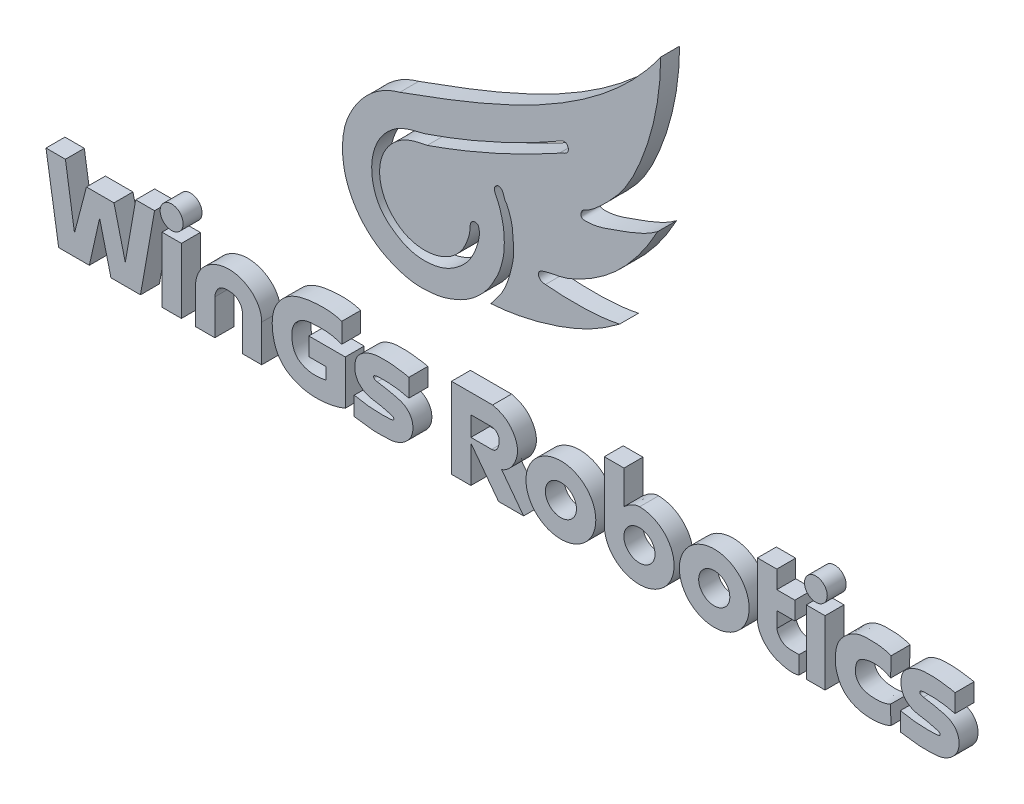
from build123d import *

# Parameters (mm, degrees)
SKETCH1_W           = 116
SKETCH1_H           = 86
BOSS_EXTRUDE1_DEPTH = 2
SKETCH2_W           = 116
SKETCH2_H           = 86
SKETCH2_W_2         = 2.050080953
SKETCH2_H_2         = 6.874434124
SKETCH2_R           = 1.213859124
SKETCH2_W_3         = 1.981029746
SKETCH2_H_3         = 6.809423223
SKETCH2_R_2         = 1.204225855
CUT_EXTRUDE2_DEPTH  = 11


with BuildPart() as part:
    # Sketch1 → Boss-Extrude1 (new body)
    with BuildSketch(Plane.XY):
        with Locations((58, 43)):
            Rectangle(SKETCH1_W, SKETCH1_H)
    extrude(amount=BOSS_EXTRUDE1_DEPTH)

    # Sketch2 → Cut-Extrude2 (cut)
    with BuildSketch(Plane.XY.offset(2)):
        with Locations((58, 43)):
            Rectangle(SKETCH2_W, SKETCH2_H)
        Polygon((11.140293702, 19.790279863), (9.80265223, 28.23498876), (11.852733183, 28.23498876), (12.812345543, 21.968429251), (14.07728911, 26.810109799), (16.985205355, 26.810109799), (18.177451016, 21.968429251), (19.282459189, 28.23498876), (21.274381817, 28.23498876), (19.785291617, 19.790279863), (16.665334568, 19.790279863), (15.467765439, 24.653578889), (14.382620316, 19.790279863), align=None, mode=Mode.SUBTRACT)
        with Locations((23.08455968, 23.227496925)):
            Rectangle(SKETCH2_W_2, SKETCH2_H_2, mode=Mode.SUBTRACT)
        with Locations((23.077289889, 28.540319965)):
            Circle(SKETCH2_R, mode=Mode.SUBTRACT)
        with BuildLine():
            add(Edge.make_bspline(
                [(25.597182949, 23.698574699), (25.655024383, 24.365774688), (26.094095564, 25.511687071), (27.542408981, 26.573688518), (30.276837479, 27.206654041), (32.573603491, 25.561936036), (32.593329118, 23.698574699)],
                knots=[0, 0, 0, 0, 0.198571456, 0.340640158, 0.513500481, 1, 1, 1, 1], degree=3))
            Line((32.593329118, 23.698574699), (32.593329118, 19.790279863))
            Line((32.593329118, 19.790279863), (30.550507488, 19.790279863))
            Line((30.550507488, 19.790279863), (30.550507488, 23.53425261))
            add(Edge.make_bspline(
                [(30.550507488, 23.53425261), (30.543410322, 23.975896739), (30.106824896, 24.716492763), (29.076011424, 24.858477486), (28.007386667, 24.772266409), (27.672864704, 23.933055449), (27.642687936, 23.53425261)],
                knots=[0, 0, 0, 0, 0.311205264, 0.495487823, 0.702071237, 1, 1, 1, 1], degree=3))
            Line((27.642687936, 23.53425261), (27.642687936, 19.790279863))
            Line((27.642687936, 19.790279863), (25.597182949, 19.790279863))
            Line((25.597182949, 19.790279863), (25.597182949, 23.698574699))
        make_face(mode=Mode.SUBTRACT)
        with BuildLine():
            Line((41.424471902, 24.925589684), (41.424471902, 20.231702472))
            add(Edge.make_bspline(
                [(41.058476828, 28.008964275), (40.053420622, 28.339513511), (38.252788176, 28.348289283), (35.579957653, 27.861823316), (33.807127389, 26.011782786), (33.590864529, 23.48949894), (34.259884703, 21.082821932), (36.595364, 19.679501372), (39.068594523, 19.5440089), (40.723497475, 19.936398387), (41.424471902, 20.231702472)],
                knots=[0, 0, 0, 0, 0.156695014, 0.267521344, 0.399378103, 0.502861963, 0.63762312, 0.747872283, 0.886034629, 1, 1, 1, 1], degree=3))
            Line((41.058476828, 28.008964275), (41.058476828, 25.902909309))
            add(Edge.make_bspline(
                [(39.392903947, 21.787154833), (38.709328807, 21.648731932), (37.576908234, 21.542273573), (36.102464246, 22.345223797), (35.704866734, 23.743461009), (35.813146547, 25.200823073), (36.969778747, 26.203973561), (38.234458734, 26.273280017), (39.623410218, 26.318179205), (40.523608068, 26.087789356), (41.058476828, 25.902909309)],
                knots=[0, 0, 0, 0, 0.18146663, 0.284134985, 0.402884015, 0.534993454, 0.639880998, 0.765013074, 0.852735118, 1, 1, 1, 1], degree=3))
            Line((39.392903947, 21.787154833), (39.392903947, 23.026010695))
            Line((39.392903947, 23.026010695), (37.575915349, 23.026010695))
            Line((37.575915349, 23.026010695), (37.575915349, 24.925589684))
            Line((37.575915349, 24.925589684), (41.424471902, 24.925589684))
        make_face(mode=Mode.SUBTRACT)
        with BuildLine():
            add(Edge.make_bspline(
                [(44.806139371, 24.345586206), (45.423564394, 24.273968664), (46.288006885, 24.064813555), (47.46290877, 23.806737598), (48.147012509, 23.319049527), (48.545595153, 22.590177306), (48.619598313, 21.763304801), (48.319682406, 20.806370209), (47.572161935, 20.139557196), (46.608821821, 19.710816999), (45.568962771, 19.681190723), (44.121341532, 19.640413074), (43.061307266, 19.870150262), (42.372568114, 19.942636104)],
                knots=[0, 0, 0, 0, 0.150365809, 0.21715787, 0.290606041, 0.346071454, 0.414260527, 0.486930119, 0.581715223, 0.647372918, 0.740088904, 0.830726665, 1, 1, 1, 1], degree=3))
            Line((42.372568114, 19.942636104), (42.372568114, 21.90410986))
            add(Edge.make_bspline(
                [(42.372568114, 21.90410986), (42.852483981, 21.803658023), (43.540520525, 21.684742464), (44.478218307, 21.597026122), (45.194509725, 21.588266366), (45.868754908, 21.582787144), (46.30052186, 21.631307616), (46.529651689, 21.687660928), (46.556676317, 21.797012759), (46.552265055, 21.96425316), (46.37902786, 22.020999474), (46.317322138, 22.049037935)],
                knots=[0, 0, 0, 0, 0.315552381, 0.449832635, 0.605449321, 0.778844328, 0.876434538, 0.897820479, 0.917220083, 0.942476197, 1, 1, 1, 1], degree=3))
            add(Edge.make_bspline(
                [(46.317322138, 22.049037935), (45.824731993, 22.210742689), (44.975778867, 22.40163227), (43.648132153, 22.55699702), (42.701652483, 23.251908996), (42.420499941, 24.163498462), (42.431107022, 24.854255388), (42.572538443, 25.490668332), (43.004076818, 26.004420138), (43.507908782, 26.358764483), (44.109433868, 26.601004045), (44.74426891, 26.734288086), (45.445562789, 26.743327695), (46.262343534, 26.742582693), (47.164011558, 26.592971419), (47.832474332, 26.519558956), (48.148216766, 26.428077311)],
                knots=[0, 0, 0, 0, 0.129354314, 0.216840147, 0.332807427, 0.395281765, 0.447955501, 0.504878839, 0.55358992, 0.611567985, 0.657300196, 0.714661081, 0.77238727, 0.832100329, 0.918345636, 1, 1, 1, 1], degree=3))
            Line((48.148216766, 26.428077311), (48.148216766, 24.517425483))
            add(Edge.make_bspline(
                [(48.148216766, 24.517425483), (46.54397318, 24.945679792), (44.888792958, 24.852708279)],
                knots=[0, 0, 0, 1, 1, 1], degree=2))
            add(Edge.make_bspline(
                [(44.888792958, 24.852708279), (44.689182117, 24.848786999), (44.51078328, 24.752820598)],
                knots=[0, 0, 0, 1, 1, 1], degree=2))
            add(Edge.make_bspline(
                [(44.51078328, 24.752820598), (44.406308103, 24.717681376), (44.387924492, 24.412408384), (44.702186936, 24.383832223), (44.806139371, 24.345586206)],
                knots=[0, 0, 0, 0, 0.400794389, 1, 1, 1, 1], degree=3))
        make_face(mode=Mode.SUBTRACT)
        with BuildLine():
            add(Edge.make_bspline(
                [(56.993288194, 28.316464094), (57.507888583, 28.199947411), (58.406020002, 27.861332004), (59.304855599, 26.802490907), (59.764827962, 25.5392533), (59.345117638, 23.970677964), (58.578129601, 23.113462352), (57.950903995, 22.876918969)],
                knots=[0, 0, 0, 0, 0.21664701, 0.372499043, 0.551296922, 0.738033031, 1, 1, 1, 1], degree=3))
            Line((57.950903995, 22.876918969), (60.268122243, 19.79950217))
            Line((60.268122243, 19.79950217), (57.623356652, 19.79950217))
            Line((57.623356652, 19.79950217), (54.699102304, 23.683102457))
            Line((54.699102304, 23.683102457), (54.699102304, 19.79950217))
            Line((54.699102304, 19.79950217), (52.650010924, 19.79950217))
            Line((52.650010924, 19.79950217), (52.650010924, 28.316464094))
            Line((52.650010924, 28.316464094), (56.993288194, 28.316464094))
        make_face(mode=Mode.SUBTRACT)
        with BuildLine():
            add(Edge.make_bspline(
                [(60.520652519, 23.223770711), (60.520652519, 17.012049197), (66.052713203, 20.117909954), (71.584773886, 23.223770711), (66.052713203, 26.329631468), (60.520652519, 29.435492225), (60.520652519, 23.223770711)],
                knots=[0, 0, 0, 2.094395102, 2.094395102, 4.188790205, 4.188790205, 6.283185307, 6.283185307, 6.283185307], degree=2, weights=[1, 0.5, 1, 0.5, 1, 0.5, 1]))
        make_face(mode=Mode.SUBTRACT)
        with BuildLine():
            Line((68.819382849, 23.63112519), (68.793403111, 29.486042678))
            Line((68.793403111, 29.486042678), (70.875700117, 29.486042678))
            Line((70.875700117, 29.486042678), (70.875700117, 25.957189376))
            add(Edge.make_bspline(
                [(70.875700117, 25.957189376), (71.166477188, 26.20926662), (71.655724283, 26.56346003), (72.234921297, 26.761658442), (72.450088475, 26.768760138)],
                knots=[0, 0, 0, 0, 0.616176335, 0.959930277, 0.959930277, 0.959930277, 0.959930277], degree=3))
            add(Edge.make_bspline(
                [(72.450088475, 26.768760138), (72.475169465, 26.769587948), (72.500355825, 26.769547878), (72.525641569, 26.768570447)],
                knots=[0.959930277, 0.959930277, 0.959930277, 0.959930277, 1, 1, 1, 1], degree=3))
            add(Edge.make_bspline(
                [(68.819382849, 23.63112519), (67.662000297, 14.258830949), (74.941664532, 20.549874967), (82.00157216, 26.651006588), (72.525641569, 26.768570447)],
                knots=[6.176447512, 6.176447512, 6.176447512, 8.596254133, 8.596254133, 10.989752867, 10.989752867, 10.989752867], degree=2, weights=[1, 0.353109864, 1, 0.360142786, 0.986087077]))
        make_face(mode=Mode.SUBTRACT)
        with BuildLine():
            add(Edge.make_bspline(
                [(76.723043602, 23.258188157), (76.723043602, 17.046466643), (82.255104285, 20.1523274), (87.787164969, 23.258188157), (82.255104285, 26.364048914), (76.723043602, 29.469909671), (76.723043602, 23.258188157)],
                knots=[0, 0, 0, 2.094395102, 2.094395102, 4.188790205, 4.188790205, 6.283185307, 6.283185307, 6.283185307], degree=2, weights=[1, 0.5, 1, 0.5, 1, 0.5, 1]))
        make_face(mode=Mode.SUBTRACT)
        with BuildLine():
            Line((84.974819681, 22.876918969), (84.974819681, 28.316464094))
            Line((84.974819681, 28.316464094), (87.019259344, 28.316464094))
            Line((87.019259344, 28.316464094), (87.019259344, 26.428077311))
            Line((87.019259344, 26.428077311), (88.927403029, 26.428077311))
            Line((88.927403029, 26.428077311), (88.927403029, 24.517425483))
            Line((88.927403029, 24.517425483), (87.019259344, 24.517425483))
            Line((87.019259344, 24.517425483), (87.019259344, 22.876918969))
            add(Edge.make_bspline(
                [(89.369700044, 21.656437237), (88.886440556, 21.681452245), (88.103178845, 21.552378339), (87.281716916, 22.165179144), (87.087153612, 22.617862686), (87.019259344, 22.876918969)],
                knots=[0, 0, 0, 0, 0.514659913, 0.724878499, 1, 1, 1, 1], degree=3))
            Line((89.369700044, 21.656437237), (89.369700044, 19.790279863))
            add(Edge.make_bspline(
                [(87.019259344, 20.009497646), (87.764844995, 19.766104306), (88.592472755, 19.517741572), (89.369700044, 19.790279863)],
                knots=[0, 0, 0, 0, 1, 1, 1, 1], degree=3))
            add(Edge.make_bspline(
                [(84.974819681, 22.876918969), (84.904874023, 21.581617108), (85.880370875, 20.470748303), (87.019259344, 20.009497646)],
                knots=[0, 0, 0, 0, 1, 1, 1, 1], degree=3))
        make_face(mode=Mode.SUBTRACT)
        with Locations((91.132775555, 23.194991475)):
            Rectangle(SKETCH2_W_3, SKETCH2_H_3, mode=Mode.SUBTRACT)
        with BuildLine():
            add(Edge.make_bspline(
                [(99.107363386, 26.428077311), (98.706813514, 26.570619476), (98.057086859, 26.739047265), (97.144064108, 26.769744551), (96.425929948, 26.789005977), (95.6235266, 26.680118298), (94.766663587, 26.291049934), (94.018726516, 25.642257941), (93.394133402, 24.752120489), (93.19884016, 23.708895909), (93.18851624, 22.662055822), (93.450358204, 21.640092766), (94.692233145, 19.432342362), (97.670513165, 19.369727476), (99.076222909, 20.009497646)],
                knots=[0, 0, 0, 0, 0.080031766, 0.124597918, 0.17129882, 0.21488749, 0.275500126, 0.344981473, 0.39882164, 0.47645066, 0.539473476, 0.594476939, 0.673244535, 1, 1, 1, 1], degree=3))
            Line((99.107363386, 26.428077311), (99.045082433, 24.345586206))
            add(Edge.make_bspline(
                [(99.045082433, 24.345586206), (98.140817478, 24.917670358), (96.933385238, 25.010368916), (95.962175283, 24.517425483)],
                knots=[0, 0, 0, 0, 1, 1, 1, 1], degree=3))
            add(Edge.make_bspline(
                [(95.962175283, 24.517425483), (95.590503523, 24.35964368), (95.371380246, 23.80674187), (95.284997638, 23.024137326), (95.465768646, 22.395754832), (95.907523378, 21.960247649), (96.471324165, 21.728931484), (97.52614725, 21.584707283), (98.434101144, 21.657237599), (99.045082433, 21.968429251)],
                knots=[0, 0, 0, 0, 0.178931515, 0.272004473, 0.383258516, 0.483726003, 0.563109197, 0.676720983, 1, 1, 1, 1], degree=3))
            Line((99.045082433, 21.968429251), (99.076222909, 20.009497646))
        make_face(mode=Mode.SUBTRACT)
        with Locations((91.149003897, 28.540319965)):
            Circle(SKETCH2_R_2, mode=Mode.SUBTRACT)
        with BuildLine():
            add(Edge.make_bspline(
                [(102.515237443, 24.338180385), (103.132662467, 24.266562843), (103.997104957, 24.057407734), (105.172006842, 23.799331777), (105.856110582, 23.311643706), (106.254693225, 22.582771485), (106.328696385, 21.75589898), (106.028780479, 20.798964389), (105.281260008, 20.132151375), (104.317919893, 19.703411179), (103.278060843, 19.673784902), (101.830439604, 19.633007253), (100.770405338, 19.862744441), (100.081666186, 19.935230284)],
                knots=[0, 0, 0, 0, 0.150365809, 0.21715787, 0.290606041, 0.346071454, 0.414260527, 0.486930119, 0.581715223, 0.647372918, 0.740088904, 0.830726665, 1, 1, 1, 1], degree=3))
            Line((100.081666186, 19.935230284), (100.081666186, 21.89670404))
            add(Edge.make_bspline(
                [(100.081666186, 21.89670404), (100.561582053, 21.796252202), (101.249618597, 21.677336643), (102.18731638, 21.589620301), (102.903607798, 21.580860546), (103.57785298, 21.575381323), (104.009619933, 21.623901795), (104.238749761, 21.680255107), (104.265774389, 21.789606938), (104.261363127, 21.95684734), (104.088125932, 22.013593653), (104.02642021, 22.041632114)],
                knots=[0, 0, 0, 0, 0.315552381, 0.449832635, 0.605449321, 0.778844328, 0.876434538, 0.897820479, 0.917220083, 0.942476197, 1, 1, 1, 1], degree=3))
            add(Edge.make_bspline(
                [(104.02642021, 22.041632114), (103.533830066, 22.203336869), (102.68487694, 22.394226449), (101.357230225, 22.5495912), (100.410750556, 23.244503176), (100.129598013, 24.156092641), (100.140205094, 24.846849567), (100.281636516, 25.483262512), (100.71317489, 25.997014317), (101.217006854, 26.351358662), (101.81853194, 26.593598224), (102.453366982, 26.726882265), (103.154660861, 26.735921874), (103.971441607, 26.735176872), (104.87310963, 26.585565598), (105.541572404, 26.512153135), (105.857314838, 26.420671491)],
                knots=[0, 0, 0, 0, 0.129354314, 0.216840147, 0.332807427, 0.395281765, 0.447955501, 0.504878839, 0.55358992, 0.611567985, 0.657300196, 0.714661081, 0.77238727, 0.832100329, 0.918345636, 1, 1, 1, 1], degree=3))
            Line((105.857314838, 26.420671491), (105.857314838, 24.510019662))
            add(Edge.make_bspline(
                [(105.857314838, 24.510019662), (104.253071252, 24.938273972), (102.59789103, 24.845302458)],
                knots=[0, 0, 0, 1, 1, 1], degree=2))
            add(Edge.make_bspline(
                [(102.59789103, 24.845302458), (102.398280189, 24.841381178), (102.219881352, 24.745414777)],
                knots=[0, 0, 0, 1, 1, 1], degree=2))
            add(Edge.make_bspline(
                [(102.219881352, 24.745414777), (102.115406175, 24.710275556), (102.097022564, 24.405002563), (102.411285008, 24.376426403), (102.515237443, 24.338180385)],
                knots=[0, 0, 0, 0, 0.400794389, 1, 1, 1, 1], degree=3))
        make_face(mode=Mode.SUBTRACT)
        with BuildLine():
            add(Edge.make_bspline(
                [(58.454232807, 47.516375152), (58.155201107, 47.766256761), (58.242612626, 48.405648514), (57.63435824, 48.725818852), (57.33951575, 48.561080563), (57.148056352, 48.331669293), (57.191833565, 47.968880637), (57.373109598, 47.594828313), (57.64633552, 47.047787141), (57.835821816, 46.438243828), (58.054855682, 45.66789616), (58.183227128, 44.904585404), (58.245836004, 43.851782874), (58.214820236, 42.740629424), (57.93171993, 41.583185887), (57.630830141, 40.625252894), (57.159571505, 39.759385244), (56.516222929, 38.60157538), (55.42470024, 37.436336943), (54.116750982, 36.463653396), (52.894350187, 35.923293203), (51.77243295, 35.514319825), (50.450751358, 35.31741506), (48.783731824, 35.237164884), (46.898690964, 35.69687239), (44.924093636, 36.617380122), (43.161708961, 38.106675964), (42.003804738, 39.901498444), (41.341001552, 41.702039563), (41.031458158, 43.795886426), (41.241639988, 46.031174435), (42.353202792, 48.424037338), (44.089054597, 50.650061335), (46.063860923, 51.731417101), (47.183080217, 52.026795225)],
                knots=[0, 0, 0, 0, 0.025484439, 0.03338283, 0.040232234, 0.046589479, 0.052344178, 0.063458754, 0.074883627, 0.093534169, 0.106469828, 0.129018368, 0.145624842, 0.177759685, 0.20359143, 0.225939601, 0.245354605, 0.270053463, 0.315285484, 0.351906237, 0.379454707, 0.405318365, 0.432327032, 0.469428533, 0.517419701, 0.561659463, 0.615846213, 0.670886596, 0.70401842, 0.744828345, 0.813276794, 0.851640065, 0.922150279, 1, 1, 1, 1], degree=3))
            add(Edge.make_bspline(
                [(47.183080217, 52.026795225), (57.216006345, 55.660419078), (68.349060224, 59.914176828), (74.752380083, 69.037208456)],
                knots=[0, 0, 0, 0, 1, 1, 1, 1], degree=3))
            add(Edge.make_bspline(
                [(74.752380083, 69.037208456), (74.736480386, 65.365885816), (73.727785029, 60.42570916), (70.966298428, 54.814242003), (68.758137434, 52.543762288), (67.300781423, 51.259360355), (66.385730313, 50.889179194), (66.191919274, 50.032187732), (67.340500179, 50.051911847), (68.580710142, 50.28254762), (71.142874018, 51.242375338), (73.213453076, 51.977233393), (74.434250991, 52.903399761)],
                knots=[0, 0, 0, 0, 0.360634108, 0.500005098, 0.614901621, 0.674581887, 0.691796307, 0.711226794, 0.738155757, 0.775635724, 0.851125952, 1, 1, 1, 1], degree=3))
            add(Edge.make_bspline(
                [(74.434250991, 52.903399761), (73.534437389, 51.244569181), (71.936292943, 48.870628445), (69.171720948, 46.226278325), (66.812856972, 44.685192365), (64.459018347, 43.563749511), (62.770947443, 43.441981971), (61.838513719, 43.010318867), (61.79284973, 42.33300121), (62.305978307, 42.117953901), (62.575531023, 42.134455593)],
                knots=[0, 0, 0, 0, 0.317486122, 0.477470025, 0.639062499, 0.792072541, 0.904921088, 0.928219039, 0.952009601, 1, 1, 1, 1], degree=3))
            add(Edge.make_bspline(
                [(62.575531023, 42.134455593), (63.354690243, 42.053803072), (64.7000675, 41.991387353), (66.708351282, 41.980958204), (68.546303226, 42.102590199), (69.809212082, 42.294223653), (70.410675427, 42.422660643)],
                knots=[0, 0, 0, 0, 0.298501271, 0.513417608, 0.765547662, 1, 1, 1, 1], degree=3))
            add(Edge.make_bspline(
                [(70.410675427, 42.422660643), (69.072158185, 41.392849447), (66.673523302, 39.95664783), (63.113718316, 38.677885822), (60.018889064, 37.859420378), (57.920946683, 37.5757846), (56.811430016, 37.503961117)],
                knots=[0, 0, 0, 0, 0.345508658, 0.567873889, 0.772356782, 1, 1, 1, 1], degree=3))
            add(Edge.make_bspline(
                [(56.811430016, 37.503961117), (57.150102419, 38.014022677), (57.987255556, 38.904490686), (58.613227549, 40.422973363), (59.012652401, 41.840922862), (59.290272897, 43.220897632), (59.160816631, 44.408188822), (59.11246086, 45.885792368), (58.773408264, 46.827837511), (58.454232807, 47.516375152)],
                knots=[0, 0, 0, 0, 0.1719112, 0.337536146, 0.453261138, 0.586013532, 0.727876697, 0.785410912, 1, 1, 1, 1], degree=3))
        make_face(mode=Mode.SUBTRACT)
        with BuildLine():
            add(Edge.make_bspline(
                [(56.811430016, 26.274566068), (57.165142546, 26.312013915), (57.762696052, 25.857331641), (57.662984423, 24.819667856), (57.332468607, 24.193202864), (56.894826652, 24.204529659)],
                knots=[0, 0, 0, 0, 0.345185418, 0.626260613, 1, 1, 1, 1], degree=3))
            Line((56.811430016, 26.274566068), (54.699102304, 26.274566068))
            Line((54.699102304, 26.274566068), (54.699102304, 24.204529659))
            Line((54.699102304, 24.204529659), (56.894826652, 24.204529659))
        make_face()
        with BuildLine():
            add(Edge.make_bspline(
                [(62.575531023, 23.026010695), (62.911473441, 20.251696721), (65.19324516, 21.935493732), (67.475016879, 23.619290743), (64.857302742, 24.709807706), (62.239588605, 25.80032467), (62.575531023, 23.026010695)],
                knots=[0, 0, 0, 2.094395102, 2.094395102, 4.188790205, 4.188790205, 6.283185307, 6.283185307, 6.283185307], degree=2, weights=[1, 0.5, 1, 0.5, 1, 0.5, 1]))
        make_face()
        with BuildLine():
            add(Edge.make_bspline(
                [(70.875700117, 23.037387122), (71.211642535, 20.263073147), (73.493414254, 21.946870158), (75.775185973, 23.630667169), (73.157471836, 24.721184133), (70.539757699, 25.811701097), (70.875700117, 23.037387122)],
                knots=[0, 0, 0, 2.094395102, 2.094395102, 4.188790205, 4.188790205, 6.283185307, 6.283185307, 6.283185307], degree=2, weights=[1, 0.5, 1, 0.5, 1, 0.5, 1]))
        make_face()
        with BuildLine():
            add(Edge.make_bspline(
                [(78.777922105, 23.060428141), (79.113864523, 20.286114166), (81.395636242, 21.969911177), (83.677407961, 23.653708188), (81.059693824, 24.744225152), (78.441979687, 25.834742116), (78.777922105, 23.060428141)],
                knots=[0, 0, 0, 2.094395102, 2.094395102, 4.188790205, 4.188790205, 6.283185307, 6.283185307, 6.283185307], degree=2, weights=[1, 0.5, 1, 0.5, 1, 0.5, 1]))
        make_face()
        with BuildLine():
            add(Edge.make_bspline(
                [(64.349924674, 56.161374818), (64.469308928, 56.198038689), (64.738228566, 56.247793356), (64.929809958, 55.987135025), (65.02677974, 55.728006959), (64.891079963, 55.148714005), (64.273965083, 55.054702659), (64.038603905, 54.882342772)],
                knots=[0, 0, 0, 0, 0.180534732, 0.288784375, 0.393192125, 0.542413532, 1, 1, 1, 1], degree=3))
            add(Edge.make_bspline(
                [(64.349924674, 56.161374818), (57.438497294, 52.157653387), (49.814342424, 49.548665095)],
                knots=[0, 0, 0, 1, 1, 1], degree=2))
            add(Edge.make_bspline(
                [(49.814342424, 49.548665095), (49.164290041, 49.378401155), (48.212436546, 49.196059818), (46.372347391, 48.377280304), (44.219210093, 46.16100786), (43.977382754, 42.604306322), (45.225353462, 40.052494882), (46.595117348, 38.914609571), (48.298977569, 37.990831076), (50.179012631, 37.837873079), (52.012731798, 38.232040281), (53.395544621, 39.100170897), (54.501661681, 40.189216921), (55.187854158, 41.482764429), (55.562081954, 42.679754198), (55.631497641, 43.576813671), (55.453855705, 44.128916533), (55.208034601, 44.116133089)],
                knots=[0, 0, 0, 0, 0.074166524, 0.105399841, 0.22059516, 0.394008221, 0.454413258, 0.527731026, 0.585288596, 0.665338457, 0.728527594, 0.788515133, 0.842168303, 0.897127647, 0.948286442, 0.97672011, 1, 1, 1, 1], degree=3))
            add(Edge.make_bspline(
                [(55.208034601, 44.116133089), (55.022625143, 44.179137333), (54.667036382, 43.958988589), (54.609396177, 43.464246826), (54.597765617, 42.863626491), (54.34232087, 42.009327553), (53.776372018, 40.734234474), (52.329674774, 39.33758596), (50.15244427, 38.721390022), (47.705197676, 39.133153699), (45.93028533, 40.62158031), (44.977495317, 42.793991738), (45.042833315, 45.537264714), (47.124443032, 48.008216113), (49.205962332, 48.468704925), (50.074487372, 48.612115737)],
                knots=[0, 0, 0, 0, 0.023492855, 0.044042325, 0.061062078, 0.101136052, 0.156797186, 0.239209866, 0.350065975, 0.433770548, 0.549578037, 0.629423488, 0.732521354, 0.886290578, 1, 1, 1, 1], degree=3))
            add(Edge.make_bspline(
                [(64.038603905, 54.882342772), (59.572034383, 52.406223373), (54.900103059, 50.294759316), (50.074487372, 48.612115737)],
                knots=[0, 0, 0, 0, 1, 1, 1, 1], degree=3))
        make_face()
    extrude(amount=-CUT_EXTRUDE2_DEPTH, mode=Mode.SUBTRACT)


with BuildPart() as cut_extrude2_piece_1:
    # of the separate pieces the step leaves, piece 1, a body of its own (cut_extrude2_pieces)
    add(part.part.solids().sort_by_distance((74.752380083, 69.037208456, 0))[0])


with BuildPart() as cut_extrude2_piece_2:
    # of the separate pieces the step leaves, piece 2, a body of its own (cut_extrude2_pieces)
    add(part.part.solids().sort_by_distance((11.140293702, 19.790279863, 0))[0])


with BuildPart() as cut_extrude2_piece_3:
    # of the separate pieces the step leaves, piece 3, a body of its own (cut_extrude2_pieces)
    add(part.part.solids().sort_by_distance((41.424471902, 24.925589684, 0))[0])


with BuildPart() as cut_extrude2_piece_4:
    # of the separate pieces the step leaves, piece 4, a body of its own (cut_extrude2_pieces)
    add(part.part.solids().sort_by_distance((57.950903995, 22.876918969, 0))[0])


with BuildPart() as cut_extrude2_piece_5:
    # of the separate pieces the step leaves, piece 5, a body of its own (cut_extrude2_pieces)
    add(part.part.solids().sort_by_distance((68.819382849, 23.63112519, 0))[0])


with BuildPart() as cut_extrude2_piece_6:
    # of the separate pieces the step leaves, piece 6, a body of its own (cut_extrude2_pieces)
    add(part.part.solids().sort_by_distance((76.723043602, 23.258188157, 0))[0])


with BuildPart() as cut_extrude2_piece_7:
    # of the separate pieces the step leaves, piece 7, a body of its own (cut_extrude2_pieces)
    add(part.part.solids().sort_by_distance((60.520652519, 23.223770711, 0))[0])


with BuildPart() as cut_extrude2_piece_8:
    # of the separate pieces the step leaves, piece 8, a body of its own (cut_extrude2_pieces)
    add(part.part.solids().sort_by_distance((42.372568114, 19.942636104, 0))[0])


with BuildPart() as cut_extrude2_piece_9:
    # of the separate pieces the step leaves, piece 9, a body of its own (cut_extrude2_pieces)
    add(part.part.solids().sort_by_distance((100.081666186, 19.935230284, 0))[0])


with BuildPart() as cut_extrude2_piece_10:
    # of the separate pieces the step leaves, piece 10, a body of its own (cut_extrude2_pieces)
    add(part.part.solids().sort_by_distance((32.593329118, 23.698574699, 0))[0])


with BuildPart() as cut_extrude2_piece_11:
    # of the separate pieces the step leaves, piece 11, a body of its own (cut_extrude2_pieces)
    add(part.part.solids().sort_by_distance((99.045082433, 21.968429251, 0))[0])


with BuildPart() as cut_extrude2_piece_12:
    # of the separate pieces the step leaves, piece 12, a body of its own (cut_extrude2_pieces)
    add(part.part.solids().sort_by_distance((84.974819681, 22.876918969, 0))[0])


with BuildPart() as cut_extrude2_piece_13:
    # of the separate pieces the step leaves, piece 13, a body of its own (cut_extrude2_pieces)
    add(part.part.solids().sort_by_distance((22.059519203, 19.790279863, 0))[0])


with BuildPart() as cut_extrude2_piece_14:
    # of the separate pieces the step leaves, piece 14, a body of its own (cut_extrude2_pieces)
    add(part.part.solids().sort_by_distance((90.142260682, 19.790279863, 0))[0])


with BuildPart() as cut_extrude2_piece_15:
    # of the separate pieces the step leaves, piece 15, a body of its own (cut_extrude2_pieces)
    add(part.part.solids().sort_by_distance((24.291149013, 28.540319965, 0))[0])


with BuildPart() as cut_extrude2_piece_16:
    # of the separate pieces the step leaves, piece 16, a body of its own (cut_extrude2_pieces)
    add(part.part.solids().sort_by_distance((92.353229753, 28.540319965, 0))[0])


solid = Compound([cut_extrude2_piece_1.part, cut_extrude2_piece_2.part, cut_extrude2_piece_3.part, cut_extrude2_piece_4.part, cut_extrude2_piece_5.part, cut_extrude2_piece_6.part, cut_extrude2_piece_7.part, cut_extrude2_piece_8.part, cut_extrude2_piece_9.part, cut_extrude2_piece_10.part, cut_extrude2_piece_11.part, cut_extrude2_piece_12.part, cut_extrude2_piece_13.part, cut_extrude2_piece_14.part, cut_extrude2_piece_15.part, cut_extrude2_piece_16.part])
